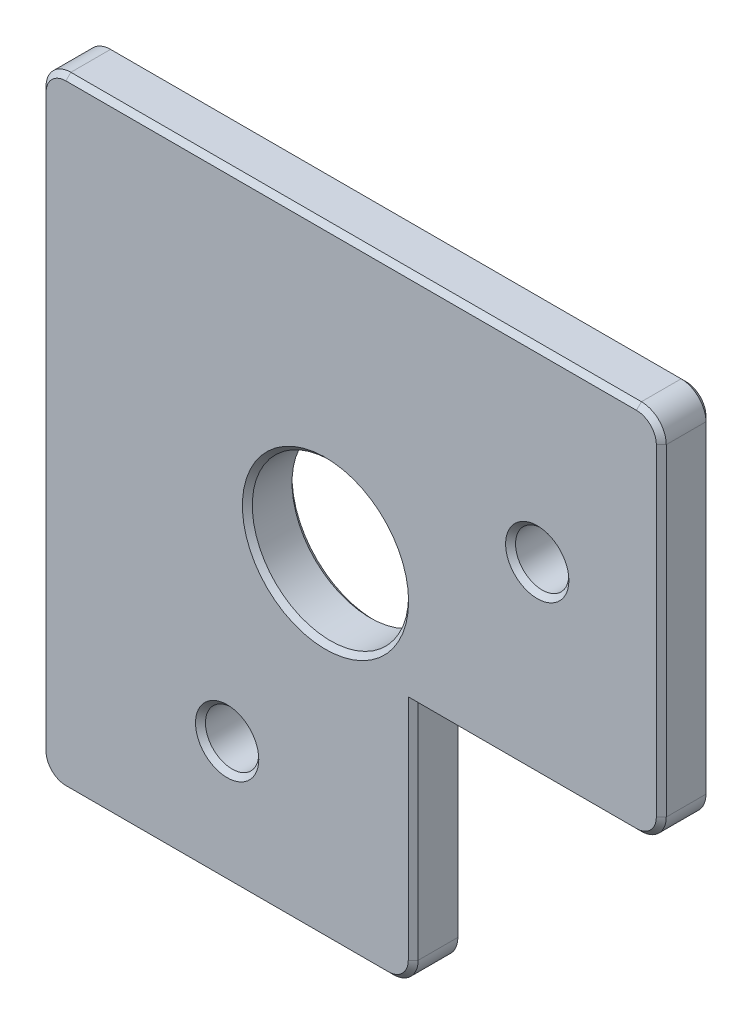
from build123d import *

# Parameters (mm, degrees)
SKETCH1_R           = 2.15
SKETCH1_R_2         = 6.3
BOSS_EXTRUDE1_DEPTH = 4
FILLET1_R           = 2
CHAMFER1_SIZE       = 0.4


with BuildPart() as part:
    # Sketch1 → Boss-Extrude1 (new body)
    with BuildSketch(Plane.XY):
        Polygon((0, -50), (30, -50), (30, -30), (50, -30), (50, 0), (0, 0), align=None)
        with Locations((15, -40)):
            Circle(SKETCH1_R, mode=Mode.SUBTRACT)
        with Locations((40, -15)):
            Circle(SKETCH1_R, mode=Mode.SUBTRACT)
        with Locations((22.928932188, -22.928932188)):
            Circle(SKETCH1_R_2, mode=Mode.SUBTRACT)
    extrude(amount=BOSS_EXTRUDE1_DEPTH)

    # Fillet1
    fillet1_edges = [part.edges().sort_by_distance(p)[0] for p in [
        (0, 0, 2),
        (50, 0, 2),
        (50, -30, 2),
        (30, -50, 2),
        (0, -50, 2),
    ]]
    fillet(fillet1_edges, radius=FILLET1_R)

    # Chamfer1
    chamfer1_edges = [part.edges().sort_by_distance(p)[0] for p in [
        (39, -30, 4),
        (12.85, -40, 0),
        (12.85, -40, 4),
        (37.85, -15, 0),
        (37.85, -15, 4),
        (16.628932188, -22.928932188, 0),
        (16.628932188, -22.928932188, 4),
        (0, -25, 0),
        (0, -25, 4),
        (25, 0, 0),
        (50, -15, 0),
        (30, -39, 0),
        (15, -50, 0),
        (29.414213562, -49.414213562, 0),
        (0.585786438, -49.414213562, 0),
        (49.414213562, -29.414213562, 0),
        (49.414213562, -0.585786438, 0),
        (0.585786438, -0.585786438, 0),
        (25, 0, 4),
        (15, -50, 4),
        (30, -39, 4),
        (50, -15, 4),
        (29.414213562, -49.414213562, 4),
        (0.585786438, -49.414213562, 4),
        (49.414213562, -29.414213562, 4),
        (49.414213562, -0.585786438, 4),
        (0.585786438, -0.585786438, 4),
        (39, -30, 0),
    ]]
    chamfer(chamfer1_edges, length=CHAMFER1_SIZE)


solid = part.part
